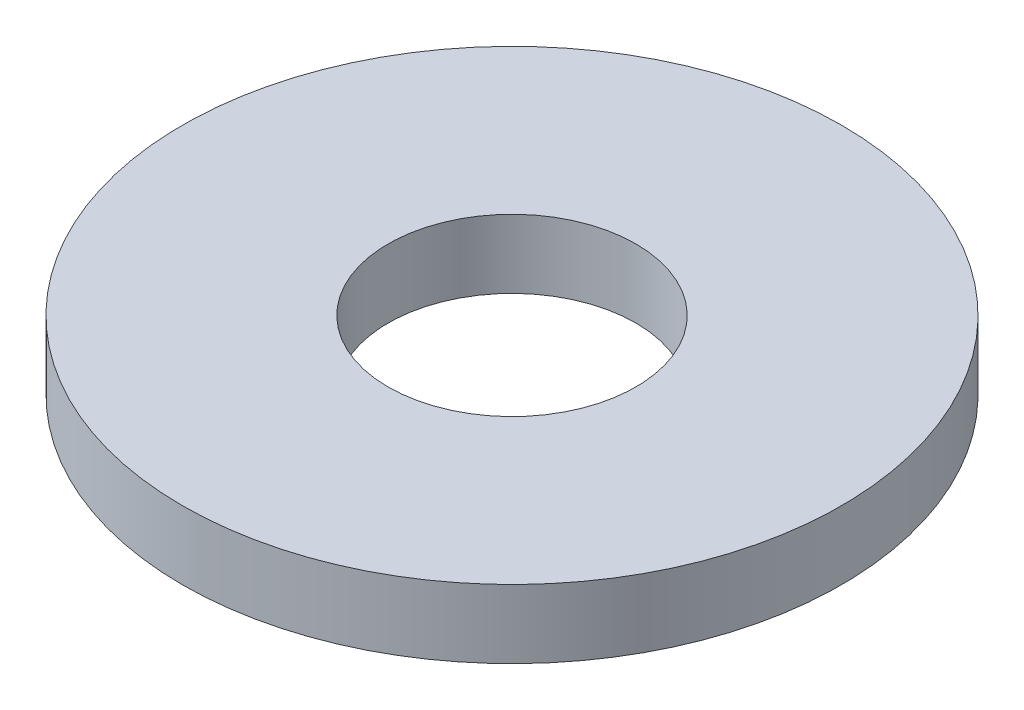
from build123d import *

# Parameters (mm, degrees)
SKETCH1_R           = 4.7625
BOSS_EXTRUDE1_DEPTH = 0.9906
SKETCH5_R           = 1.7907
CUT_EXTRUDE1_DEPTH  = 1.9906


with BuildPart() as part:
    # Sketch1 → Boss-Extrude1 (new body)
    with BuildSketch(Plane(origin=(0, 0, 0), x_dir=(1, 0, 0), z_dir=(0, 1, 0))):
        Circle(SKETCH1_R)
    extrude(amount=BOSS_EXTRUDE1_DEPTH)

    # Sketch5 → Cut-Extrude1 (cut, through all)
    with BuildSketch(Plane(origin=(0, 0.9906, 0), x_dir=(-1, 0, 0), z_dir=(0, 1, 0))):
        Circle(SKETCH5_R)
    extrude(amount=-CUT_EXTRUDE1_DEPTH, mode=Mode.SUBTRACT)


solid = part.part
